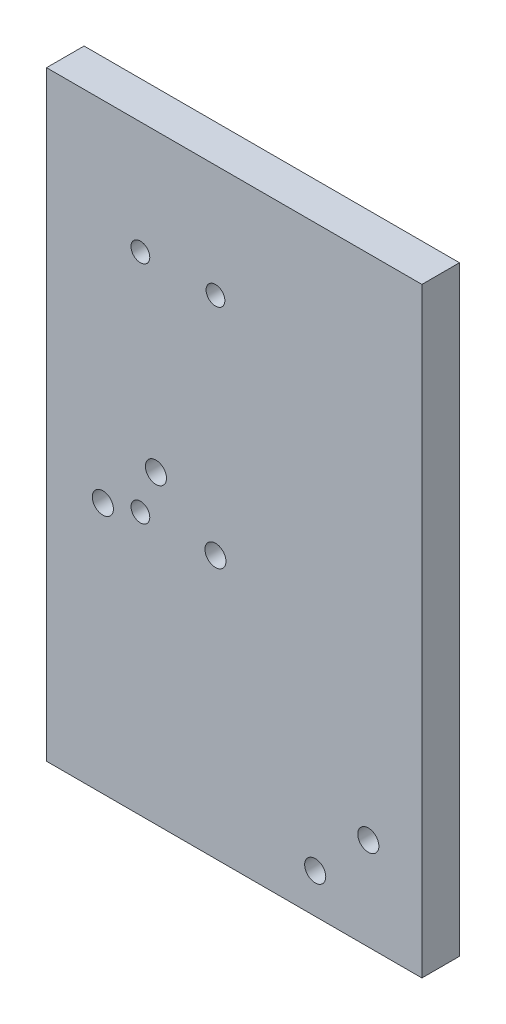
from build123d import *

# Parameters (mm, degrees)
SKETCH1_W           = 126.991036612
SKETCH1_H           = 203.20170097
SKETCH1_R           = 3.5687
SKETCH1_R_2         = 3.175
SKETCH1_R_3         = 3.556
BOSS_EXTRUDE1_DEPTH = 12.7
SKETCH2_R           = 5.5499
CUT_EXTRUDE1_DEPTH  = 7.1374


with BuildPart() as part:
    # Sketch1 → Boss-Extrude1 (new body)
    with BuildSketch(Plane.XY):
        with Locations((117.901436969, 364.776968974)):
            Rectangle(SKETCH1_W, SKETCH1_H)
        with Locations((163.258479874, 294.508127154)):
            Circle(SKETCH1_R, mode=Mode.SUBTRACT)
        with Locations((145.297967632, 276.547614912)):
            Circle(SKETCH1_R, mode=Mode.SUBTRACT)
        with Locations((91.416430905, 366.350176123)):
            Circle(SKETCH1_R, mode=Mode.SUBTRACT)
        with Locations((73.455918663, 348.389663881)):
            Circle(SKETCH1_R, mode=Mode.SUBTRACT)
        with Locations((86.155918663, 428.277819459)):
            Circle(SKETCH1_R_2, mode=Mode.SUBTRACT)
        with Locations((111.555918663, 428.277819459)):
            Circle(SKETCH1_R_2, mode=Mode.SUBTRACT)
        with Locations((86.155918663, 352.077819459)):
            Circle(SKETCH1_R_2, mode=Mode.SUBTRACT)
        with Locations((111.555918663, 352.077819459)):
            Circle(SKETCH1_R_3, mode=Mode.SUBTRACT)
    extrude(amount=BOSS_EXTRUDE1_DEPTH)

    # Sketch2 → Cut-Extrude1 (cut)
    with BuildSketch(Plane(origin=(0, 0, 0), x_dir=(-1, 0, 0), z_dir=(0, 0, -1))):
        with Locations((-91.416430905, 366.350176123)):
            Circle(SKETCH2_R)
        with Locations((-73.455918663, 348.389663881)):
            Circle(SKETCH2_R)
        with Locations((-163.258479874, 294.508127154)):
            Circle(SKETCH2_R)
        with Locations((-145.297967632, 276.547614912)):
            Circle(SKETCH2_R)
    extrude(amount=-CUT_EXTRUDE1_DEPTH, mode=Mode.SUBTRACT)


solid = part.part
